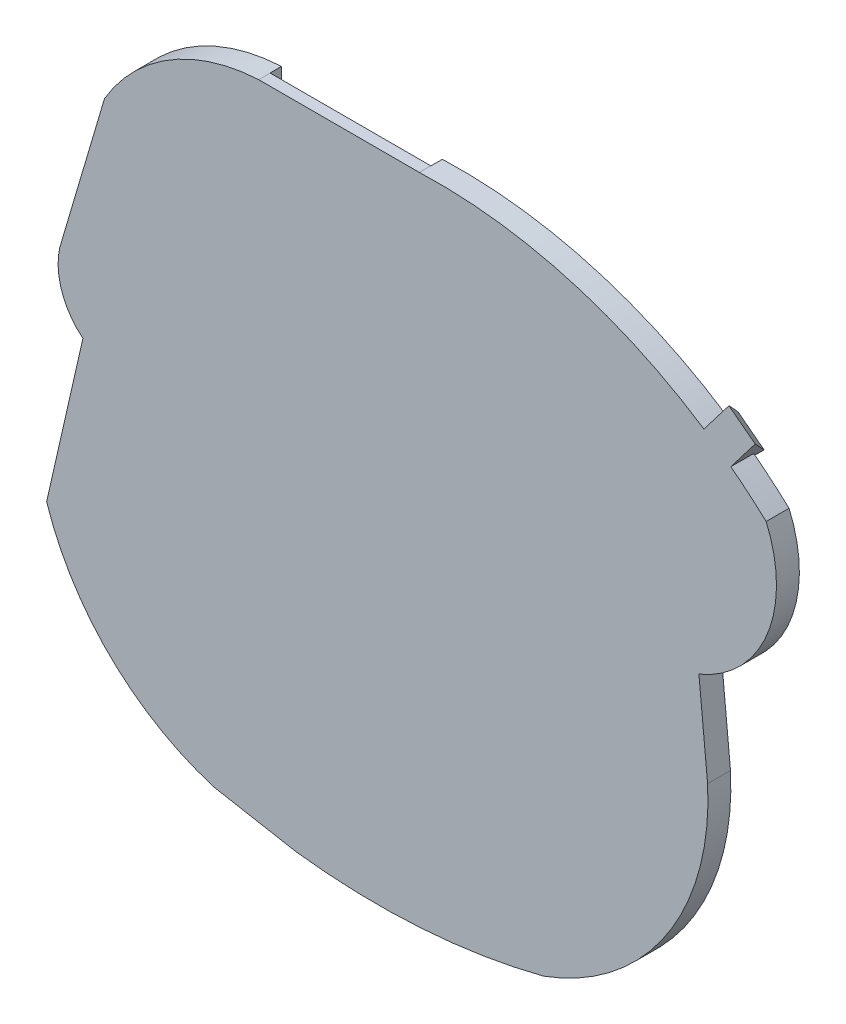
from build123d import *

# Parameters (mm, degrees)
BOSS_EXTRUDE1_DEPTH      = 2
BOSS_EXTRUDE1_DEPTH_BACK = 2
BOSS_EXTRUDE2_DEPTH      = 2
CUT_EXTRUDE2_DEPTH       = 3
BOSS_EXTRUDE3_DEPTH      = 3
BOSS_EXTRUDE3_DEPTH_BACK = 4
BOSS_EXTRUDE4_DEPTH      = 5.768626
BOSS_EXTRUDE5_DEPTH      = 7
CUT_EXTRUDE3_DEPTH       = 106.532768689


with BuildPart() as part:
    # Sketch1 → Boss-Extrude1 (new body, two sides)
    with BuildSketch(Plane.XY) as boss_extrude1_sk:
        with BuildLine():
            ThreePointArc((-99.883719426, -303.368163267), (-118.083910473, -292.687102225), (-129.239344224, -274.773746399))
            Line((-129.239344224, -274.773746399), (-122.900985764, -246.890150727))
            ThreePointArc((-122.900985764, -246.890150727), (-126.803064599, -240.933983923), (-126.548538034, -233.817990776))
            Line((-126.548538034, -233.817990776), (-119.123281802, -208.687862835))
            ThreePointArc((-119.123281802, -208.687862835), (-107.698999343, -197.140529866), (-92.168900704, -192.379105219))
            Line((-92.168900704, -192.379105219), (-64.113961972, -192.379105219))
            ThreePointArc((-64.113961972, -192.379105219), (-31.572672129, -197.617974675), (-3.509282377, -214.904601108))
            ThreePointArc((-3.509282377, -214.904601108), (-3.309447715, -231.856766436), (-15.259350681, -243.882391671))
            Line((-15.259350681, -243.882391671), (-13.742027997, -259.699185691))
            ThreePointArc((-13.742027997, -259.699185691), (-20.907511644, -286.149918063), (-42.397436123, -303.15487454))
            ThreePointArc((-42.397436123, -303.15487454), (-63.833611273, -306.582364975), (-85.533592749, -305.975652807))
            Line((-85.533592749, -305.975652807), (-99.883719426, -303.368163267))
        make_face()
        with BuildLine():
            add(Edge.make_bspline(
                [(-17.415513131, -242.668556981), (-16.250894512, -241.965818827), (-15.109288702, -241.224994889), (-13.441213679, -240.040387525), (-12.89262097, -239.633218083), (-11.812693685, -238.790317301), (-11.280400788, -238.353703672), (-9.726955108, -237.00465557), (-8.745390801, -236.051712079), (-7.385039015, -234.511313148), (-6.948715528, -233.976815867), (-6.130845571, -232.874503238), (-5.750270787, -232.30842269), (-4.706493232, -230.558637643), (-4.138677409, -229.324736835), (-3.562547958, -227.328857227), (-3.422001152, -226.654431705), (-3.252657323, -225.296308422), (-3.223357134, -224.611043663), (-3.269242402, -223.573082537), (-3.29957286, -223.227633129), (-3.388711058, -222.546593141), (-3.476993493, -222.041163228), (-3.596272382, -221.543472132), (-3.682574516, -221.213371534), (-3.730157677, -221.049427786), (-4.247949017, -219.244642568), (-4.718668417, -217.603928734), (-5.189387817, -215.9632149)],
                knots=[0, 0, 0, 0, 0.125, 0.125, 0.1875, 0.1875, 0.25, 0.25, 0.375, 0.375, 0.4375, 0.4375, 0.5, 0.5, 0.625, 0.625, 0.6875, 0.6875, 0.75, 0.75, 0.78125, 0.78125, 0.8125, 0.828125, 0.828125, 0.84375, 0.84375, 1, 1, 1, 1], degree=3))
            ThreePointArc((-5.189387817, -215.9632149), (-32.526455477, -199.407751302), (-64.08963442, -194.391340409))
            Line((-64.08963442, -194.391340409), (-92.144573152, -194.392657625))
            Line((-92.144573152, -194.392657625), (-92.202629041, -194.392657625))
            ThreePointArc((-92.202629041, -194.392657625), (-106.647929369, -198.873907617), (-117.312202813, -209.598718803))
            Line((-117.312202813, -209.598718803), (-124.435145464, -234.429494019))
            ThreePointArc((-124.435145464, -234.429494019), (-124.604366095, -241.045289532), (-120.469878975, -246.212823))
            Line((-120.469878975, -246.212823), (-121.332617267, -249.132685018))
            Line((-121.332617267, -249.132685018), (-127.264768762, -275.229302117))
            ThreePointArc((-127.264768762, -275.229302117), (-116.098302818, -291.621676712), (-98.954802842, -301.596661178))
            ThreePointArc((-98.954802842, -301.596661178), (-70.952790665, -304.90715996), (-42.984896901, -301.319820198))
            ThreePointArc((-42.984896901, -301.319820198), (-22.606132147, -285.170975908), (-15.696872441, -260.104237885))
            Line((-15.696872441, -260.104237885), (-17.415513131, -242.668556981))
        make_face(mode=Mode.SUBTRACT)
    extrude(amount=BOSS_EXTRUDE1_DEPTH)
    extrude(boss_extrude1_sk.sketch, amount=-BOSS_EXTRUDE1_DEPTH_BACK)

    # Sketch4 → Boss-Extrude2 (add)
    with BuildSketch(Plane.XY.offset(2)):
        with BuildLine():
            Line((-121.332617267, -249.132685018), (-127.264768762, -275.229302117))
            ThreePointArc((-127.264768762, -275.229302117), (-116.098302818, -291.621676712), (-98.954802842, -301.596661178))
            ThreePointArc((-98.954802842, -301.596661178), (-70.952790665, -304.90715996), (-42.984896901, -301.319820198))
            ThreePointArc((-42.984896901, -301.319820198), (-22.606132147, -285.170975908), (-15.696872441, -260.104237885))
            Line((-15.696872441, -260.104237885), (-17.415513131, -242.668556981))
            add(Edge.make_bspline(
                [(-17.415513131, -242.668556981), (-16.250894512, -241.965818827), (-15.109288702, -241.224994889), (-13.441213679, -240.040387525), (-12.89262097, -239.633218083), (-11.812693685, -238.790317301), (-11.280400788, -238.353703672), (-9.726955108, -237.00465557), (-8.745390801, -236.051712079), (-7.385039015, -234.511313148), (-6.948715528, -233.976815867), (-6.130845571, -232.874503238), (-5.750270787, -232.30842269), (-4.706493232, -230.558637643), (-4.138677409, -229.324736835), (-3.562547958, -227.328857227), (-3.422001152, -226.654431705), (-3.252657323, -225.296308422), (-3.223357134, -224.611043663), (-3.269242402, -223.573082537), (-3.29957286, -223.227633129), (-3.388711058, -222.546593141), (-3.476993493, -222.041163228), (-3.596272382, -221.543472132), (-3.682574516, -221.213371534), (-3.730157677, -221.049427786), (-4.247949017, -219.244642568), (-4.718668417, -217.603928734), (-5.189387817, -215.9632149)],
                knots=[0, 0, 0, 0, 0.125, 0.125, 0.1875, 0.1875, 0.25, 0.25, 0.375, 0.375, 0.4375, 0.4375, 0.5, 0.5, 0.625, 0.625, 0.6875, 0.6875, 0.75, 0.75, 0.78125, 0.78125, 0.8125, 0.828125, 0.828125, 0.84375, 0.84375, 1, 1, 1, 1], degree=3))
            ThreePointArc((-5.189387817, -215.9632149), (-32.526455477, -199.407751302), (-64.08963442, -194.391340409))
            Line((-64.08963442, -194.391340409), (-92.144573152, -194.392657625))
            Line((-92.144573152, -194.392657625), (-92.202629041, -194.392657625))
            ThreePointArc((-92.202629041, -194.392657625), (-106.647929369, -198.873907617), (-117.312202813, -209.598718803))
            Line((-117.312202813, -209.598718803), (-124.435145464, -234.429494019))
            ThreePointArc((-124.435145464, -234.429494019), (-124.604366095, -241.045289532), (-120.469878975, -246.212823))
            Line((-120.469878975, -246.212823), (-121.332617267, -249.132685018))
        make_face()
    extrude(amount=-BOSS_EXTRUDE2_DEPTH)

    # Sketch5 → Cut-Extrude2 (cut)
    with BuildSketch(Plane(origin=(0.009126788, -194.388330888, 0), x_dir=(0.999999999, 4.6951e-05, 0), z_dir=(4.6951e-05, -0.999999999, 0))):
        Polygon((-92.153700041, 0), (-92.21175593, 0), (-92.21175593, -2), (-92.153700041, -2), (-64.098761279, -2), (-64.098761279, 0), align=None)
    extrude(amount=-CUT_EXTRUDE2_DEPTH, mode=Mode.SUBTRACT)

    # Sketch6 → Boss-Extrude3 (add, two sides)
    with BuildSketch(Plane(origin=(0, 0, -2), x_dir=(-1, 0, 0), z_dir=(0, 0, -1))) as boss_extrude3_sk:
        with BuildLine():
            Line((10.862265169, -211.246797097), (9.680301702, -209.700960004))
            Line((9.680301702, -209.700960004), (14.382573251, -206.353642546))
            Line((14.382573251, -206.353642546), (15.461710653, -207.995655709))
            ThreePointArc((15.461710653, -207.995655709), (13.134440717, -209.582254915), (10.862265169, -211.246797097))
        make_face()
    extrude(amount=BOSS_EXTRUDE3_DEPTH)
    extrude(boss_extrude3_sk.sketch, amount=-BOSS_EXTRUDE3_DEPTH_BACK)



with BuildPart() as body_2:
    # Sketch7 → Boss-Extrude4 (new body)
    with BuildSketch(Plane(origin=(95.075403567, -72.695663841, 0), x_dir=(0, 0, -1), z_dir=(0.794394345, -0.607402358, 0))):
        with BuildLine():
            Line((-2, -172.465094912), (5, -172.465094912))
            ThreePointArc((5, -172.465094912), (2.949747468, -167.515347444), (-2, -165.465094912))
            Line((-2, -165.465094912), (-2, -172.465094912))
        make_face()
    extrude(amount=-BOSS_EXTRUDE4_DEPTH)


with BuildPart() as part_1:
    add(part.part)

    add(body_2.part)  # Boss-Extrude5 merges body 2
    # Sketch8 → Boss-Extrude5 (add)
    with BuildSketch(Plane(origin=(0, 0, -5), x_dir=(-1, 0, 0), z_dir=(0, 0, -1))):
        Polygon((14.26286593, -206.197082701), (14.382573251, -206.353642546), (9.680301702, -209.700960004), align=None)
    extrude(amount=-BOSS_EXTRUDE5_DEPTH)

    # Sketch9 → Cut-Extrude3 (cut, through all)
    with BuildSketch(Plane(origin=(95.075403567, -72.695663841, 0), x_dir=(0, 0, -1), z_dir=(0.794394345, -0.607402358, 0))):
        Polygon((-2, -165.465094912), (5, -174.411026553), (7.216406638, -174.411026553), (7.216406638, -165.465094912), align=None)
    extrude(amount=-CUT_EXTRUDE3_DEPTH, mode=Mode.SUBTRACT)


solid = part_1.part
